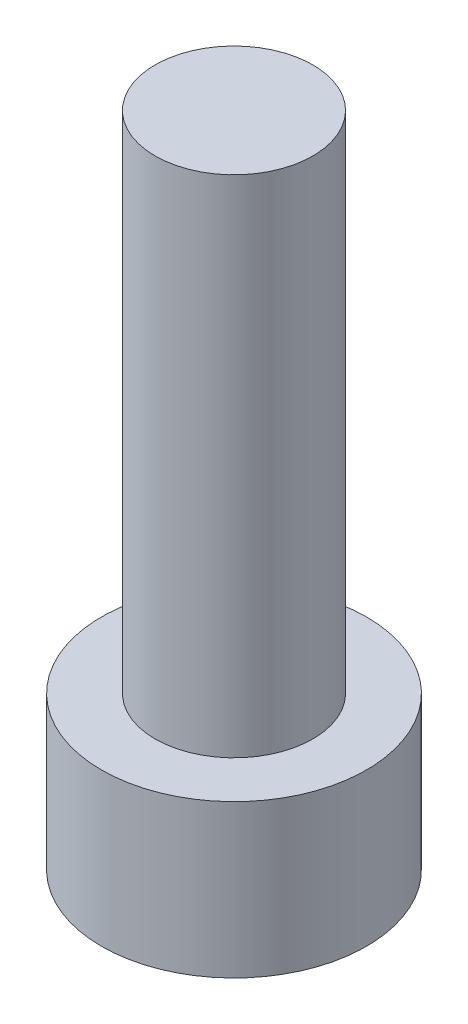
from build123d import *

# Parameters (mm, degrees)
SKETCH_1_R          = 4.2
EXTRUDE_1_DEPTH     = 4.84
SKETCH_2_R          = 2.5
EXTRUDE_2_DEPTH     = 16
CUT_EXTRUDE_1_DEPTH = 3.4


with BuildPart() as part:
    # 草图1 → 凸台-拉伸1 (new body)
    with BuildSketch(Plane(origin=(0, 0, 0), x_dir=(1, 0, 0), z_dir=(0, 1, 0))):
        Circle(SKETCH_1_R)
    extrude(amount=EXTRUDE_1_DEPTH)

    # 草图2 → 凸台-拉伸2 (add)
    with BuildSketch(Plane(origin=(0, 4.84, 0), x_dir=(1, 0, 0), z_dir=(0, 1, 0))):
        Circle(SKETCH_2_R)
    extrude(amount=EXTRUDE_2_DEPTH)

    # 草图3 → 切除-拉伸1 (cut)
    with BuildSketch(Plane.XZ):
        Polygon((2.3, 0), (1.15, 1.991858429), (-1.15, 1.991858429), (-2.3, 0), (-1.15, -1.991858429), (1.15, -1.991858429), align=None)
    extrude(amount=-CUT_EXTRUDE_1_DEPTH, mode=Mode.SUBTRACT)


solid = part.part
